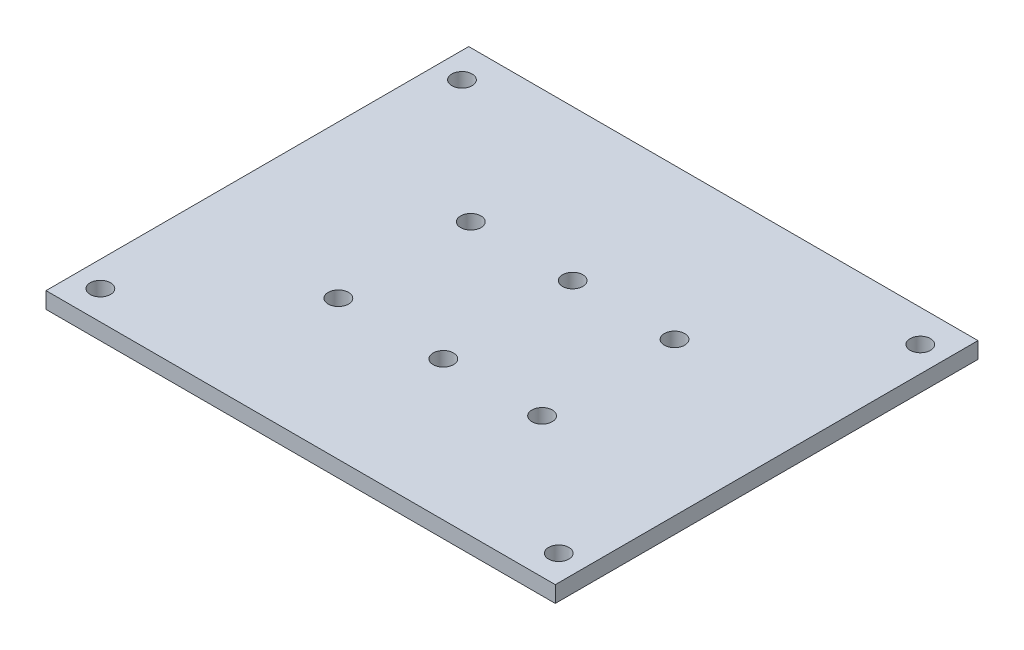
from build123d import *

# Parameters (mm, degrees)
SKETCH_1_W      = 100
SKETCH_1_H      = 83
SKETCH_1_R      = 2
EXTRUDE_1_DEPTH = 3.2


with BuildPart() as part:
    # 草图1 → 凸台-拉伸1 (new body)
    with BuildSketch(Plane(origin=(0, 0, 0), x_dir=(1, 0, 0), z_dir=(0, 1, 0))):
        with Locations((20, -16.134759455)):
            Rectangle(SKETCH_1_W, SKETCH_1_H)
        with Locations(Location((-25, 19.040242047, 0), (0, 0, 270))):  # turned: the seam where the file's is
            Circle(SKETCH_1_R, mode=Mode.SUBTRACT)
        with Locations(Location((-25, -51.959757953, 0), (0, 0, 270))):  # turned: the seam where the file's is
            Circle(SKETCH_1_R, mode=Mode.SUBTRACT)
        with Locations(Location((65, -51.959757953, 0), (0, 0, 270))):  # turned: the seam where the file's is
            Circle(SKETCH_1_R, mode=Mode.SUBTRACT)
        with Locations(Location((65, 19.040242047, 0), (0, 0, 270))):  # turned: the seam where the file's is
            Circle(SKETCH_1_R, mode=Mode.SUBTRACT)
        with Locations(Location((20, -4.225677304, 0), (0, 0, 270))):  # turned: the seam where the file's is
            Circle(SKETCH_1_R, mode=Mode.SUBTRACT)
        with Locations(Location((20.605831178, -30.225677304, 0), (0, 0, 270))):  # turned: the seam where the file's is
            Circle(SKETCH_1_R, mode=Mode.SUBTRACT)
        with Locations(Location((0, -30.225677304, 0), (0, 0, 270))):  # turned: the seam where the file's is
            Circle(SKETCH_1_R, mode=Mode.SUBTRACT)
        with Locations(Location((0, -4.225677304, 0), (0, 0, 270))):  # turned: the seam where the file's is
            Circle(SKETCH_1_R, mode=Mode.SUBTRACT)
        with Locations(Location((40, -4.225677304, 0), (0, 0, 270))):  # turned: the seam where the file's is
            Circle(SKETCH_1_R, mode=Mode.SUBTRACT)
        with Locations(Location((40, -30.225677304, 0), (0, 0, 270))):  # turned: the seam where the file's is
            Circle(SKETCH_1_R, mode=Mode.SUBTRACT)
    extrude(amount=EXTRUDE_1_DEPTH)


solid = part.part
